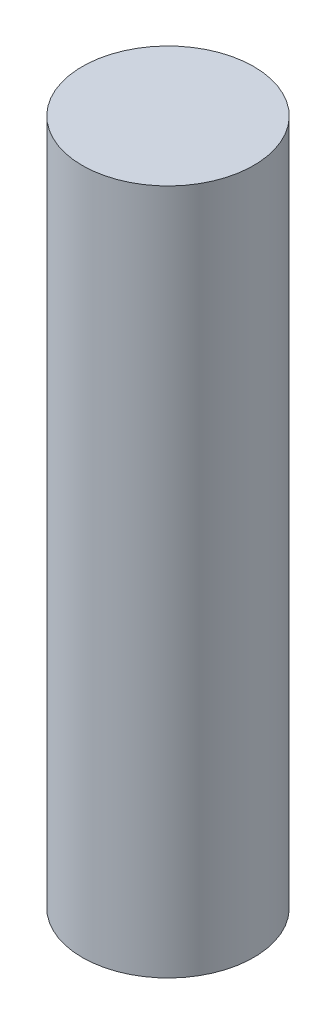
from build123d import *

# Parameters (mm, degrees)
ESQUISSE2_R      = 1.25
EXTRUSION1_DEPTH = 10


with BuildPart() as part:
    # Esquisse2 → Extrusion1 (new body)
    with BuildSketch(Plane.XZ.offset(-4.657558322)):
        with Locations((-0.389434894, -13.47998185)):
            Circle(ESQUISSE2_R)
    extrude(amount=EXTRUSION1_DEPTH)


solid = part.part
